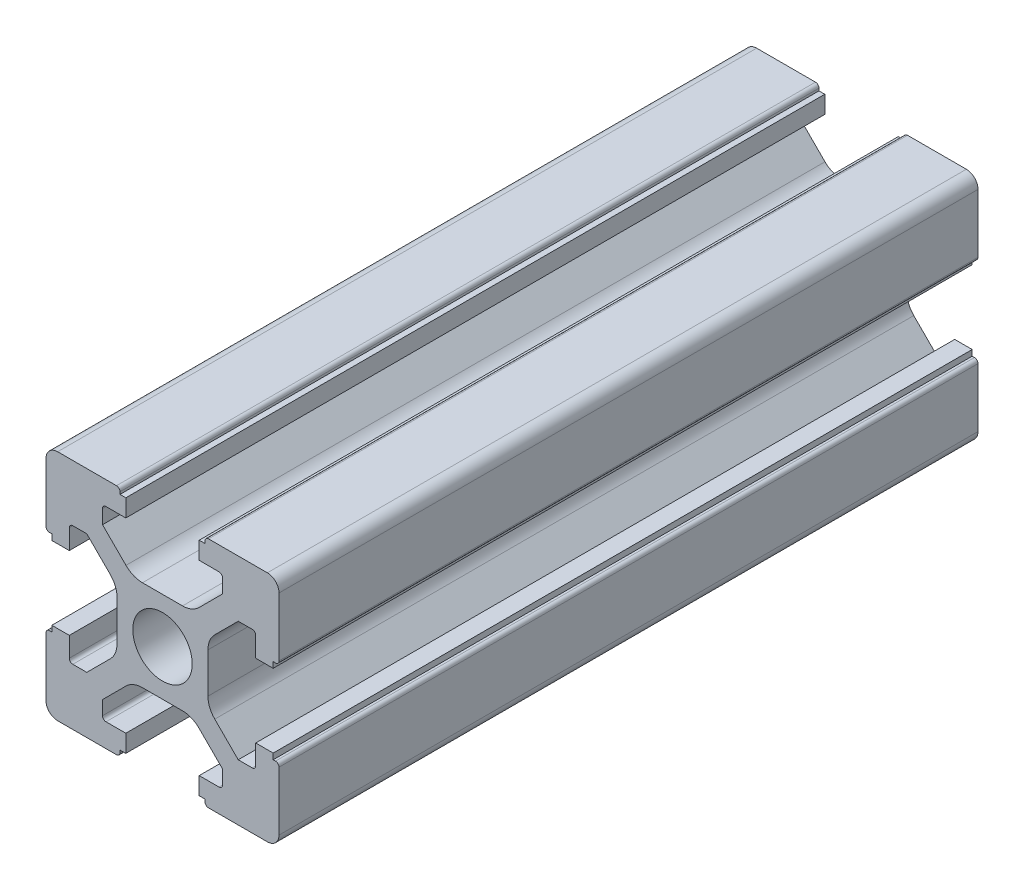
from build123d import *

# Parameters (mm, degrees)
SKETCH_1_RX     = 2.55
SKETCH_1_RY     = 2.55
EXTRUDE_1_DEPTH = 60


with BuildPart() as part:
    # 草图1 → 凸台-拉伸1 (new body)
    with BuildSketch(Plane.XY):
        with BuildLine():
            Line((-10, -9), (-10, -3.95))
            add(Edge.make_bspline(
                [(-9.7, -3.65), (-10, -3.65), (-10, -3.95)],
                knots=[4.71238898, 4.71238898, 4.71238898, 6.283185307, 6.283185307, 6.283185307], degree=2, weights=[1, 0.707106781, 1]))
            Line((-9.7, -3.65), (-9.5, -3.65))
            Line((-9.5, -3.65), (-9.5, -3.15))
            Line((-9.5, -3.15), (-8, -3.15))
            Line((-8, -3.15), (-8, -4.85))
            add(Edge.make_bspline(
                [(-8, -4.85), (-8, -5.15), (-7.7, -5.15)],
                knots=[3.141592654, 3.141592654, 3.141592654, 4.71238898, 4.71238898, 4.71238898], degree=2, weights=[1, 0.707106781, 1]))
            Line((-7.7, -5.15), (-6.5, -5.15))
            Line((-6.5, -5.15), (-4.485786438, -3.135786438))
            add(Edge.make_bspline(
                [(-4.485786438, -3.135786438), (-3.9, -2.55), (-3.9, -1.721572875)],
                knots=[0.785398163, 0.785398163, 0.785398163, 1.570796327, 1.570796327, 1.570796327], degree=2, weights=[1, 0.923879533, 1]))
            Line((-3.9, -1.721572875), (-3.9, 1.721572875))
            add(Edge.make_bspline(
                [(-3.9, 1.721572875), (-3.9, 2.55), (-4.485786438, 3.135786438)],
                knots=[0, 0, 0, 0.785398163, 0.785398163, 0.785398163], degree=2, weights=[1, 0.923879533, 1]))
            Line((-4.485786438, 3.135786438), (-6.5, 5.15))
            Line((-6.5, 5.15), (-7.7, 5.15))
            add(Edge.make_bspline(
                [(-7.7, 5.15), (-8, 5.15), (-8, 4.85)],
                knots=[1.570796327, 1.570796327, 1.570796327, 3.141592654, 3.141592654, 3.141592654], degree=2, weights=[1, 0.707106781, 1]))
            Line((-8, 4.85), (-8, 3.15))
            Line((-8, 3.15), (-9.5, 3.15))
            Line((-9.5, 3.15), (-9.5, 3.65))
            Line((-9.5, 3.65), (-9.7, 3.65))
            add(Edge.make_bspline(
                [(-10, 3.95), (-10, 3.65), (-9.7, 3.65)],
                knots=[3.141592654, 3.141592654, 3.141592654, 4.71238898, 4.71238898, 4.71238898], degree=2, weights=[1, 0.707106781, 1]))
            Line((-10, 3.95), (-10, 9))
            add(Edge.make_bspline(
                [(-9, 10), (-10, 10), (-10, 9)],
                knots=[4.71238898, 4.71238898, 4.71238898, 6.283185307, 6.283185307, 6.283185307], degree=2, weights=[1, 0.707106781, 1]))
            Line((-9, 10), (-3.95, 10))
            add(Edge.make_bspline(
                [(-3.65, 9.7), (-3.65, 10), (-3.95, 10)],
                knots=[0, 0, 0, 1.570796327, 1.570796327, 1.570796327], degree=2, weights=[1, 0.707106781, 1]))
            Line((-3.65, 9.7), (-3.65, 9.5))
            Line((-3.65, 9.5), (-3.15, 9.5))
            Line((-3.15, 9.5), (-3.15, 8))
            Line((-3.15, 8), (-4.85, 8))
            add(Edge.make_bspline(
                [(-4.85, 8), (-5.15, 8), (-5.15, 7.7)],
                knots=[1.570796327, 1.570796327, 1.570796327, 3.141592654, 3.141592654, 3.141592654], degree=2, weights=[1, 0.707106781, 1]))
            Line((-5.15, 7.7), (-5.15, 6.5))
            Line((-5.15, 6.5), (-3.135786438, 4.485786438))
            add(Edge.make_bspline(
                [(-3.135786438, 4.485786438), (-2.55, 3.9), (-1.721572875, 3.9)],
                knots=[3.926990817, 3.926990817, 3.926990817, 4.71238898, 4.71238898, 4.71238898], degree=2, weights=[1, 0.923879533, 1]))
            Line((-1.721572875, 3.9), (1.721572875, 3.9))
            add(Edge.make_bspline(
                [(1.721572875, 3.9), (2.55, 3.9), (3.135786438, 4.485786438)],
                knots=[1.570796327, 1.570796327, 1.570796327, 2.35619449, 2.35619449, 2.35619449], degree=2, weights=[1, 0.923879533, 1]))
            Line((3.135786438, 4.485786438), (5.15, 6.5))
            Line((5.15, 6.5), (5.15, 7.7))
            add(Edge.make_bspline(
                [(5.15, 7.7), (5.15, 8), (4.85, 8)],
                knots=[4.71238898, 4.71238898, 4.71238898, 6.283185307, 6.283185307, 6.283185307], degree=2, weights=[1, 0.707106781, 1]))
            Line((4.85, 8), (3.15, 8))
            Line((3.15, 8), (3.15, 9.5))
            Line((3.15, 9.5), (3.65, 9.5))
            Line((3.65, 9.5), (3.65, 9.7))
            add(Edge.make_bspline(
                [(3.95, 10), (3.65, 10), (3.65, 9.7)],
                knots=[0, 0, 0, 1.570796327, 1.570796327, 1.570796327], degree=2, weights=[1, 0.707106781, 1]))
            Line((3.95, 10), (9, 10))
            add(Edge.make_bspline(
                [(10, 9), (10, 10), (9, 10)],
                knots=[0, 0, 0, 1.570796327, 1.570796327, 1.570796327], degree=2, weights=[1, 0.707106781, 1]))
            Line((10, 9), (10, 3.95))
            add(Edge.make_bspline(
                [(9.7, 3.65), (10, 3.65), (10, 3.95)],
                knots=[4.71238898, 4.71238898, 4.71238898, 6.283185307, 6.283185307, 6.283185307], degree=2, weights=[1, 0.707106781, 1]))
            Line((9.7, 3.65), (9.5, 3.65))
            Line((9.5, 3.65), (9.5, 3.15))
            Line((9.5, 3.15), (8, 3.15))
            Line((8, 3.15), (8, 4.85))
            add(Edge.make_bspline(
                [(8, 4.85), (8, 5.15), (7.7, 5.15)],
                knots=[3.141592654, 3.141592654, 3.141592654, 4.71238898, 4.71238898, 4.71238898], degree=2, weights=[1, 0.707106781, 1]))
            Line((7.7, 5.15), (6.5, 5.15))
            Line((6.5, 5.15), (4.485786438, 3.135786438))
            add(Edge.make_bspline(
                [(4.485786438, 3.135786438), (3.9, 2.55), (3.9, 1.721572875)],
                knots=[2.35619449, 2.35619449, 2.35619449, 3.141592654, 3.141592654, 3.141592654], degree=2, weights=[1, 0.923879533, 1]))
            Line((3.9, 1.721572875), (3.9, -1.721572875))
            add(Edge.make_bspline(
                [(3.9, -1.721572875), (3.9, -2.55), (4.485786438, -3.135786438)],
                knots=[3.141592654, 3.141592654, 3.141592654, 3.926990817, 3.926990817, 3.926990817], degree=2, weights=[1, 0.923879533, 1]))
            Line((4.485786438, -3.135786438), (6.5, -5.15))
            Line((6.5, -5.15), (7.7, -5.15))
            add(Edge.make_bspline(
                [(7.7, -5.15), (8, -5.15), (8, -4.85)],
                knots=[4.71238898, 4.71238898, 4.71238898, 6.283185307, 6.283185307, 6.283185307], degree=2, weights=[1, 0.707106781, 1]))
            Line((8, -4.85), (8, -3.15))
            Line((8, -3.15), (9.5, -3.15))
            Line((9.5, -3.15), (9.5, -3.65))
            Line((9.5, -3.65), (9.7, -3.65))
            add(Edge.make_bspline(
                [(10, -3.95), (10, -3.65), (9.7, -3.65)],
                knots=[0, 0, 0, 1.570796327, 1.570796327, 1.570796327], degree=2, weights=[1, 0.707106781, 1]))
            Line((10, -3.95), (10, -9))
            add(Edge.make_bspline(
                [(9, -10), (10, -10), (10, -9)],
                knots=[4.71238898, 4.71238898, 4.71238898, 6.283185307, 6.283185307, 6.283185307], degree=2, weights=[1, 0.707106781, 1]))
            Line((9, -10), (3.95, -10))
            add(Edge.make_bspline(
                [(3.65, -9.7), (3.65, -10), (3.95, -10)],
                knots=[1.570796327, 1.570796327, 1.570796327, 3.141592654, 3.141592654, 3.141592654], degree=2, weights=[1, 0.707106781, 1]))
            Line((3.65, -9.7), (3.65, -9.5))
            Line((3.65, -9.5), (3.15, -9.5))
            Line((3.15, -9.5), (3.15, -8))
            Line((3.15, -8), (4.85, -8))
            add(Edge.make_bspline(
                [(4.85, -8), (5.15, -8), (5.15, -7.7)],
                knots=[3.141592654, 3.141592654, 3.141592654, 4.71238898, 4.71238898, 4.71238898], degree=2, weights=[1, 0.707106781, 1]))
            Line((5.15, -7.7), (5.15, -6.5))
            Line((5.15, -6.5), (3.135786438, -4.485786438))
            add(Edge.make_bspline(
                [(3.135786438, -4.485786438), (2.55, -3.9), (1.721572875, -3.9)],
                knots=[5.497787144, 5.497787144, 5.497787144, 6.283185307, 6.283185307, 6.283185307], degree=2, weights=[1, 0.923879533, 1]))
            Line((1.721572875, -3.9), (-1.721572875, -3.9))
            add(Edge.make_bspline(
                [(-1.721572875, -3.9), (-2.55, -3.9), (-3.135786438, -4.485786438)],
                knots=[0, 0, 0, 0.785398163, 0.785398163, 0.785398163], degree=2, weights=[1, 0.923879533, 1]))
            Line((-3.135786438, -4.485786438), (-5.15, -6.5))
            Line((-5.15, -6.5), (-5.15, -7.7))
            add(Edge.make_bspline(
                [(-5.15, -7.7), (-5.15, -8), (-4.85, -8)],
                knots=[3.141592654, 3.141592654, 3.141592654, 4.71238898, 4.71238898, 4.71238898], degree=2, weights=[1, 0.707106781, 1]))
            Line((-4.85, -8), (-3.15, -8))
            Line((-3.15, -8), (-3.15, -9.5))
            Line((-3.15, -9.5), (-3.65, -9.5))
            Line((-3.65, -9.5), (-3.65, -9.7))
            add(Edge.make_bspline(
                [(-3.95, -10), (-3.65, -10), (-3.65, -9.7)],
                knots=[4.71238898, 4.71238898, 4.71238898, 6.283185307, 6.283185307, 6.283185307], degree=2, weights=[1, 0.707106781, 1]))
            Line((-3.95, -10), (-9, -10))
            add(Edge.make_bspline(
                [(-10, -9), (-10, -10), (-9, -10)],
                knots=[0, 0, 0, 1.570796327, 1.570796327, 1.570796327], degree=2, weights=[1, 0.707106781, 1]))
        make_face()
        with Locations((0, 0)):
            Ellipse(SKETCH_1_RX, SKETCH_1_RY, mode=Mode.SUBTRACT)
    extrude(amount=EXTRUDE_1_DEPTH)


solid = part.part
